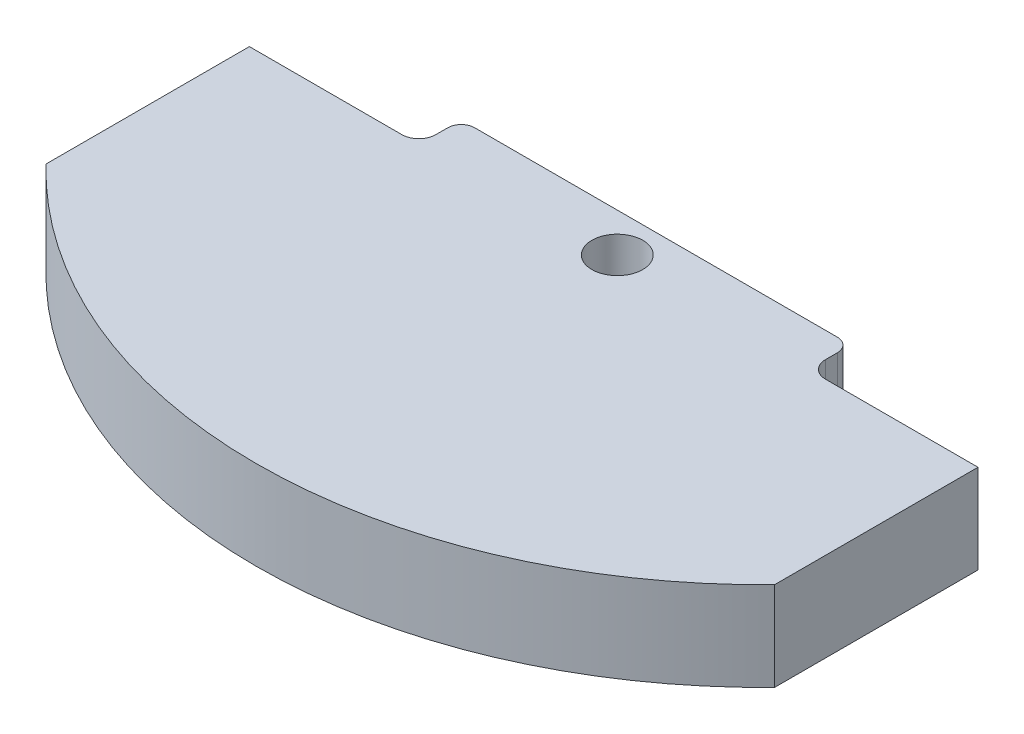
from build123d import *

# Parameters (mm, degrees)
BOSS_EXTRUDE2_DEPTH = 13.335
SKETCH10_W          = 25.4
SKETCH10_H          = 6.35
CUT_EXTRUDE1_DEPTH  = 14.335
FILLET1_R           = 2.54
FILLET2_R           = 2.032
SKETCH11_R          = 3.81
CUT_EXTRUDE2_DEPTH  = 14.335


with BuildPart() as part:
    # Sketch6 → Boss-Extrude2 (new body)
    with BuildSketch(Plane(origin=(0, 0, 0), x_dir=(1, 0, 0), z_dir=(0, 1, 0))):
        with BuildLine():
            Line((0, 0), (109.1946, 0))
            Line((109.1946, 0), (109.1946, -36.83))
            ThreePointArc((109.1946, -36.83), (54.5973, -59.960965275), (0, -36.83))
            Line((0, -36.83), (0, 0))
        make_face()
    extrude(amount=BOSS_EXTRUDE2_DEPTH)

    # Sketch10 → Cut-Extrude1 (cut, through all)
    with BuildSketch(Plane(origin=(0, 13.335, 0), x_dir=(1, 0, 0), z_dir=(0, 1, 0))):
        with Locations((96.4946, -3.175)):
            Rectangle(SKETCH10_W, SKETCH10_H)
        with Locations((12.7, -3.175)):
            Rectangle(SKETCH10_W, SKETCH10_H)
    extrude(amount=-CUT_EXTRUDE1_DEPTH, mode=Mode.SUBTRACT)

    # Fillet1
    fillet1_edges = [part.edges().sort_by_distance(p)[0] for p in [
        (25.4, 6.6675, 6.35),
        (83.7946, 6.6675, 6.35),
    ]]
    fillet(fillet1_edges, radius=FILLET1_R)

    # Fillet2
    fillet2_edges = [part.edges().sort_by_distance(p)[0] for p in [
        (25.4, 6.6675, 0),
        (83.7946, 6.6675, 0),
    ]]
    fillet(fillet2_edges, radius=FILLET2_R)

    # Sketch11 → Cut-Extrude2 (cut, through all)
    with BuildSketch(Plane.XZ):
        with Locations((54.61, 5.819375203)):
            Circle(SKETCH11_R)
    extrude(amount=-CUT_EXTRUDE2_DEPTH, mode=Mode.SUBTRACT)


solid = part.part
